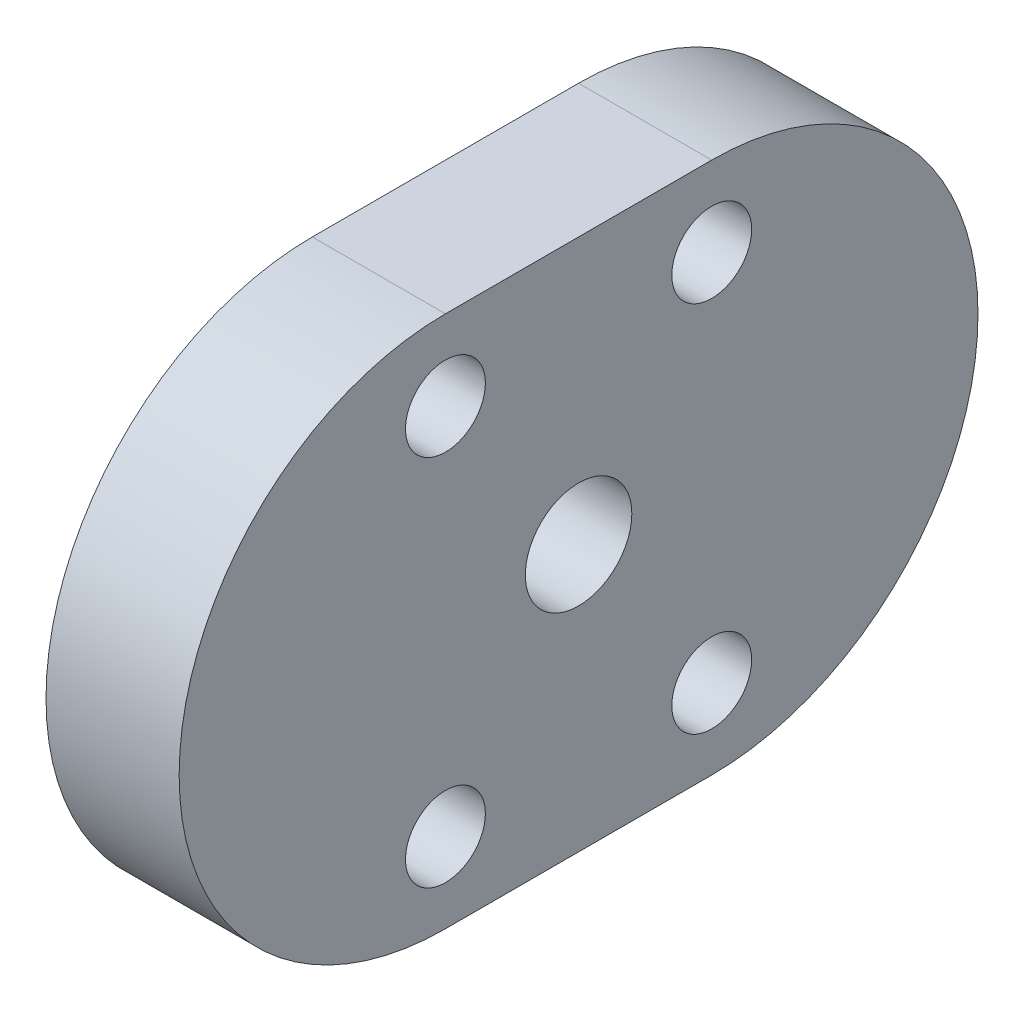
from build123d import *

# Parameters (mm, degrees)
ESTRUSIONE_ESTRUSIONE1_DEPTH = 5
SCHIZZO2_R                   = 1.5
SCHIZZO2_R_2                 = 2
TAGLIO_ESTRUSIONE1_DEPTH     = 6


with BuildPart() as part:
    # Schizzo1 → Estrusione-Estrusione1 (new body)
    with BuildSketch(Plane(origin=(0, 0, 0), x_dir=(0, 0, -1), z_dir=(1, 0, 0))):
        with BuildLine():
            Line((-5, 10), (5, 10))
            ThreePointArc((5, 10), (15, 0), (5, -10))
            Line((5, -10), (-5, -10))
            ThreePointArc((-5, -10), (-15, 0), (-5, 10))
        make_face()
    extrude(amount=ESTRUSIONE_ESTRUSIONE1_DEPTH)

    # Schizzo2 → Taglio-Estrusione1 (cut, through all)
    with BuildSketch(Plane(origin=(0, 0, 0), x_dir=(0, 0, -1), z_dir=(1, 0, 0))):
        with Locations((-5, 7)):
            Circle(SCHIZZO2_R)
        Circle(SCHIZZO2_R_2)
        with Locations((5, 7)):
            Circle(SCHIZZO2_R)
        with Locations((-5, -7)):
            Circle(SCHIZZO2_R)
        with Locations((5, -7)):
            Circle(SCHIZZO2_R)
    extrude(amount=TAGLIO_ESTRUSIONE1_DEPTH, mode=Mode.SUBTRACT)


solid = part.part
